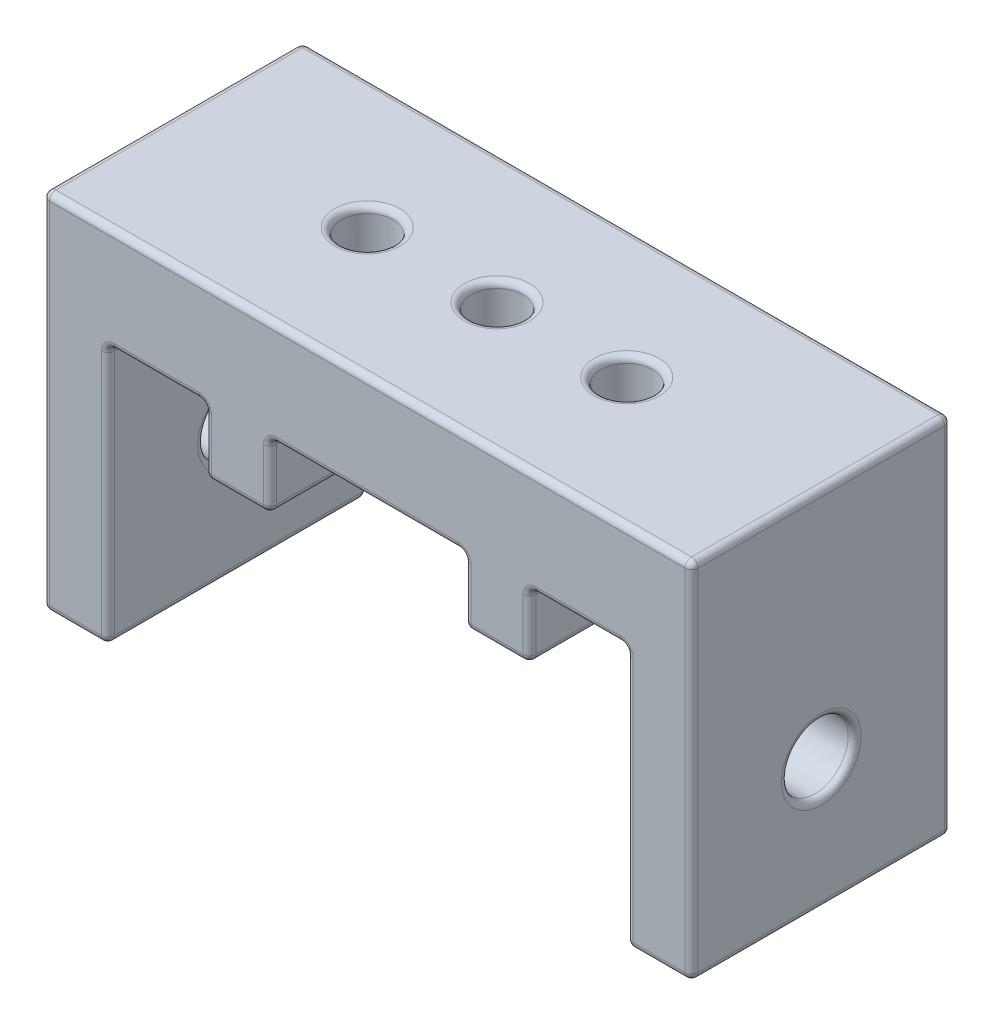
from build123d import *

# Parameters (mm, degrees)
BOSS_EXTRUDE1_DEPTH              = 25.4
SKETCH2_W                        = 6.35
SKETCH2_H                        = 7.62
BOSS_EXTRUDE2_DEPTH              = 6.35
F_1_4_20_TAPPED_HOLE1_D          = 5.1054
F_97_0_0059_DIAMETER_HOLE1_D     = 6.5278
F_97_0_0059_DIAMETER_HOLE1_DEPTH = 6.35
F_97_0_0059_DIAMETER_HOLE2_D     = 6.5278
MIRROR3_COPY_1_SKETCH_W          = 6.35
MIRROR3_COPY_1_SKETCH_H          = 7.62
MIRROR3_COPY_1_DEPTH             = 6.35
F_1_4_20_TAPPED_HOLE2_D          = 5.1054
FILLET2_R                        = 0.635


with BuildPart() as part:
    # Sketch1 → Boss-Extrude1 (new body)
    with BuildSketch(Plane.XY):
        Polygon((0, 0), (6.35, 0), (6.35, 25.4), (57.15, 25.4), (57.15, 0), (63.5, 0), (63.5, 35.56), (0, 35.56), align=None)
    extrude(amount=BOSS_EXTRUDE1_DEPTH)

    # Sketch2 → Boss-Extrude2 (add)
    with BuildSketch(Plane.XZ.offset(-25.4)):
        with Locations((19.05, 3.81)):
            Rectangle(SKETCH2_W, SKETCH2_H)
    boss_extrude2 = extrude(amount=BOSS_EXTRUDE2_DEPTH)

    # Mirror1: Boss-Extrude2 across plane
    add(boss_extrude2.mirror(Plane.XY.offset(12.7)))

    # 1/4-20 Tapped Hole1 (through all)
    with Locations(Plane(origin=(0, 35.56, 0), x_dir=(-1, 0, 0), z_dir=(0, 1, 0))):
        with Locations((-19.05, 12.7)):
            f_1_4_20_tapped_hole1 = Hole(F_1_4_20_TAPPED_HOLE1_D / 2)

    # #97 (0.0059) Diameter Hole1
    with Locations(Plane(origin=(6.35, 0, 0), x_dir=(0, 0, -1), z_dir=(1, 0, 0))):
        with Locations((-12.7, 12.7)):
            Hole(F_97_0_0059_DIAMETER_HOLE1_D / 2, depth=F_97_0_0059_DIAMETER_HOLE1_DEPTH)

    # #97 (0.0059) Diameter Hole2 (through all)
    with Locations(Plane.ZY.offset(-57.15)):
        with Locations((12.7, 12.7)):
            Hole(F_97_0_0059_DIAMETER_HOLE2_D / 2)

    # Mirror2: 1/4-20 Tapped Hole1 across plane
    add(f_1_4_20_tapped_hole1.mirror(Plane(origin=(31.75, 0, 0), x_dir=(0, 0, 1), z_dir=(1, 0, 0))), mode=Mode.SUBTRACT)

    # Mirror3: Boss-Extrude2 across plane
    add(boss_extrude2.mirror(Plane(origin=(31.75, 0, 0), x_dir=(0, 0, 1), z_dir=(1, 0, 0))))

    # Mirror3 copy 1 sketch → Mirror3 copy 1 (add)
    with BuildSketch(Plane(origin=(63.5, 25.4, 25.4), x_dir=(-1, 0, 0), z_dir=(0, -1, 0))):
        with Locations((19.05, 3.81)):
            Rectangle(MIRROR3_COPY_1_SKETCH_W, MIRROR3_COPY_1_SKETCH_H)
    extrude(amount=MIRROR3_COPY_1_DEPTH)

    # 1/4-20 Tapped Hole2 (through all)
    with Locations(Plane.XZ.offset(-25.4)):
        with Locations((31.75, 12.7)):
            Hole(F_1_4_20_TAPPED_HOLE2_D / 2)

    # Fillet2
    fillet2_edges = [part.edges().sort_by_distance(p)[0] for p in [
        (6.35, 12.7, 25.4),
        (3.175, 0, 0),
        (0, 17.78, 0),
        (11.1125, 25.4, 25.4),
        (0, 35.56, 12.7),
        (63.5, 35.56, 12.7),
        (63.5, 0, 12.7),
        (57.15, 0, 12.7),
        (57.15, 25.4, 12.7),
        (6.35, 25.4, 12.7),
        (6.35, 0, 12.7),
        (0, 0, 12.7),
        (57.15, 12.7, 25.4),
        (60.325, 0, 25.4),
        (63.5, 17.78, 25.4),
        (31.75, 25.4, 0),
        (31.75, 35.56, 25.4),
        (15.875, 25.4, 3.81),
        (15.875, 22.225, 7.62),
        (15.875, 22.225, 0),
        (22.225, 25.4, 3.81),
        (22.225, 22.225, 0),
        (19.05, 25.4, 7.62),
        (22.225, 22.225, 7.62),
        (15.875, 19.05, 3.81),
        (19.05, 19.05, 0),
        (22.225, 19.05, 3.81),
        (19.05, 19.05, 7.62),
        (31.75, 25.4, 25.4),
        (15.875, 19.05, 21.59),
        (15.875, 22.225, 25.4),
        (19.05, 19.05, 17.78),
        (15.875, 22.225, 17.78),
        (22.225, 19.05, 21.59),
        (22.225, 22.225, 17.78),
        (19.05, 19.05, 25.4),
        (22.225, 22.225, 25.4),
        (15.875, 25.4, 21.59),
        (0, 17.78, 25.4),
        (22.225, 25.4, 21.59),
        (19.05, 25.4, 17.78),
        (16.4973, 35.56, 12.7),
        (6.35, 12.7, 9.4361),
        (0, 12.7, 9.4361),
        (57.15, 12.7, 15.9639),
        (63.5, 12.7, 15.9639),
        (47.0027, 25.4, 12.7),
        (47.0027, 35.56, 12.7),
        (52.3875, 25.4, 0),
        (3.175, 0, 25.4),
        (47.625, 19.05, 3.81),
        (47.625, 22.225, 0),
        (44.45, 19.05, 7.62),
        (47.625, 22.225, 7.62),
        (41.275, 19.05, 3.81),
        (41.275, 22.225, 7.62),
        (44.45, 19.05, 0),
        (41.275, 22.225, 0),
        (47.625, 25.4, 3.81),
        (41.275, 25.4, 3.81),
        (44.45, 25.4, 7.62),
        (31.75, 35.56, 0),
        (52.3875, 25.4, 25.4),
        (63.5, 17.78, 0),
        (47.625, 25.4, 21.59),
        (47.625, 22.225, 17.78),
        (47.625, 22.225, 25.4),
        (41.275, 25.4, 21.59),
        (41.275, 22.225, 25.4),
        (44.45, 25.4, 17.78),
        (41.275, 22.225, 17.78),
        (47.625, 19.05, 21.59),
        (44.45, 19.05, 25.4),
        (41.275, 19.05, 21.59),
        (44.45, 19.05, 17.78),
        (60.325, 0, 0),
        (57.15, 12.7, 0),
        (11.1125, 25.4, 0),
        (6.35, 12.7, 0),
        (34.3027, 25.4, 12.7),
        (34.3027, 35.56, 12.7),
    ]]
    fillet(fillet2_edges, radius=FILLET2_R)


solid = part.part
